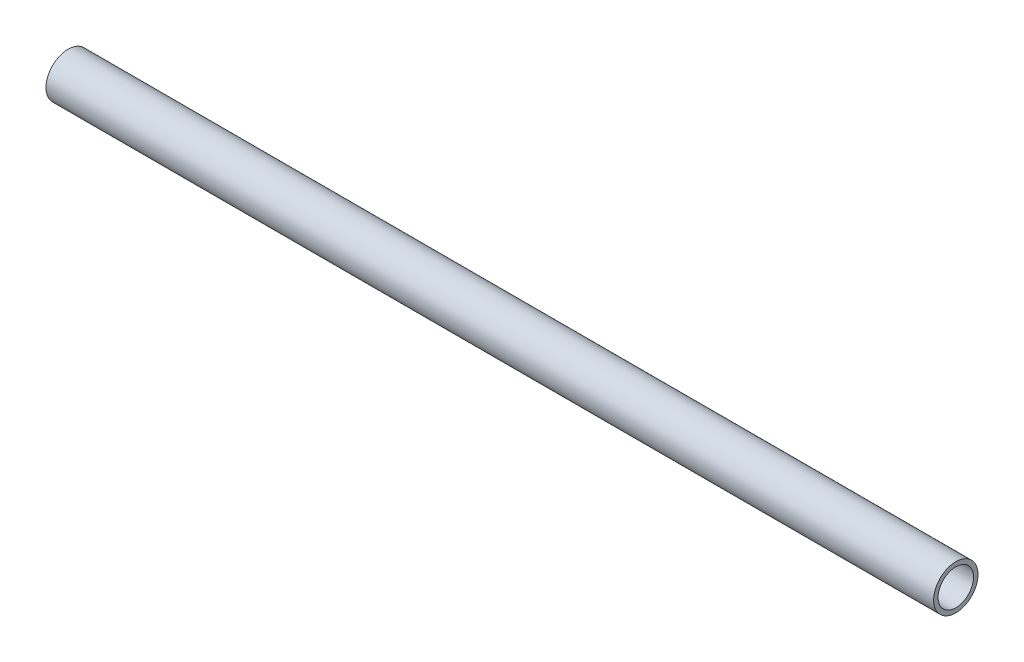
from build123d import *

# Parameters (mm, degrees)
SKETCH1_R           = 5
SKETCH1_R_2         = 4
BOSS_EXTRUDE1_DEPTH = 200


with BuildPart() as part:
    # Sketch1 → Boss-Extrude1 (new body)
    with BuildSketch(Plane(origin=(0, 0, 0), x_dir=(0, 0, -1), z_dir=(1, 0, 0))):
        Circle(SKETCH1_R)
        Circle(SKETCH1_R_2, mode=Mode.SUBTRACT)
    extrude(amount=BOSS_EXTRUDE1_DEPTH)


solid = part.part
